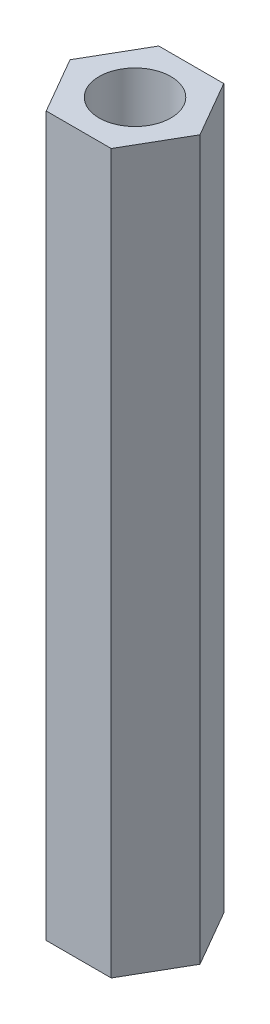
from build123d import *

# Parameters (mm, degrees)
SKETCH_1_R      = 1.5
EXTRUDE_1_DEPTH = 30


with BuildPart() as part:
    # 草图1 → 凸台-拉伸1 (new body)
    with BuildSketch(Plane(origin=(0, 0, 0), x_dir=(1, 0, 0), z_dir=(0, 1, 0))):
        Polygon((2.713546265, 0), (1.356773133, 2.35), (-1.356773133, 2.35), (-2.713546265, 0), (-1.356773133, -2.35), (1.356773133, -2.35), align=None)
        Circle(SKETCH_1_R, mode=Mode.SUBTRACT)
    extrude(amount=EXTRUDE_1_DEPTH)


solid = part.part
